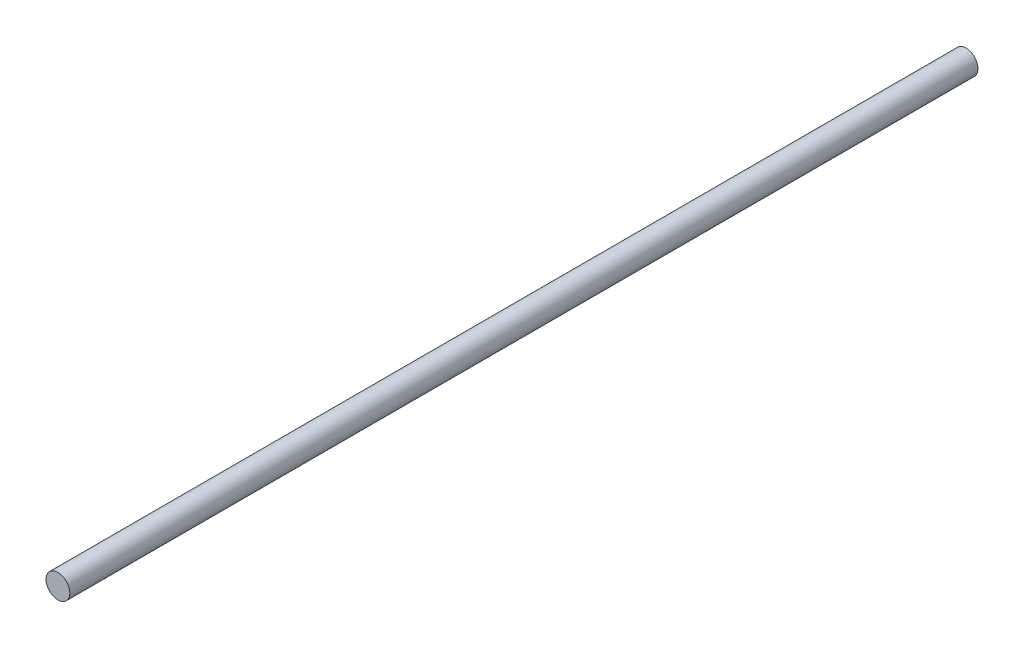
from build123d import *

# Parameters (mm, degrees)
SKETCH3_R                = 0.625
BOSS_EXTRUDE1_DEPTH      = 23.8125
BOSS_EXTRUDE1_DEPTH_BACK = 23.8125


with BuildPart() as part:
    # Sketch3 → Boss-Extrude1 (new body, two sides)
    with BuildSketch(Plane.XY) as boss_extrude1_sk:
        Circle(SKETCH3_R)
    extrude(amount=BOSS_EXTRUDE1_DEPTH)
    extrude(boss_extrude1_sk.sketch, amount=-BOSS_EXTRUDE1_DEPTH_BACK)


solid = part.part
